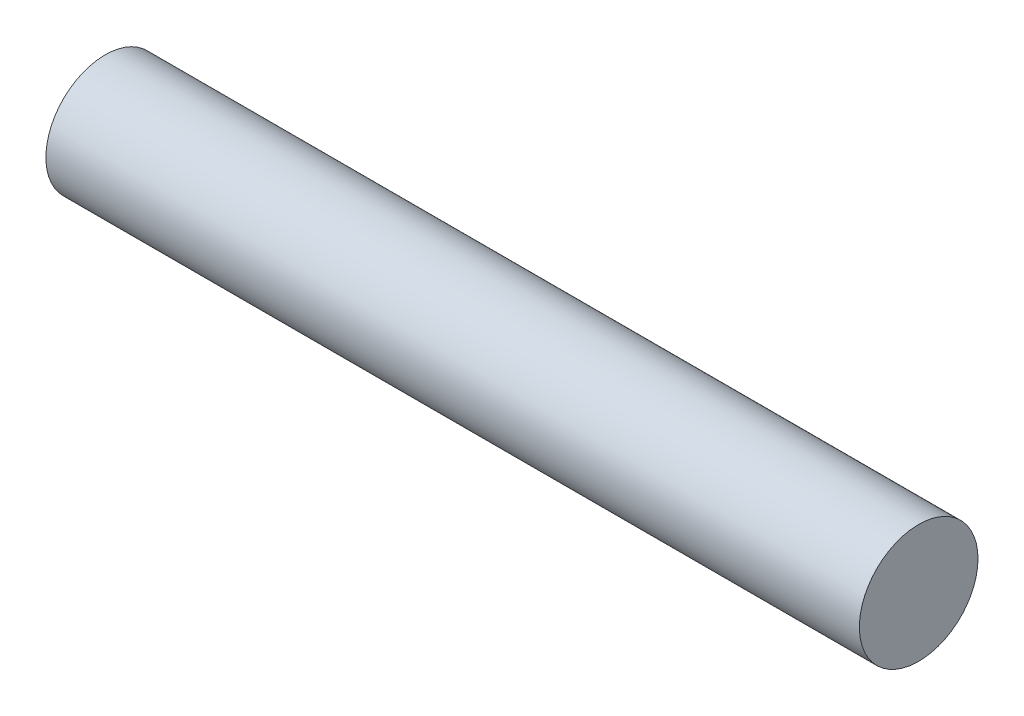
from build123d import *

# Parameters (mm, degrees)
SKETCH1_R           = 11.1125
BOSS_EXTRUDE1_DEPTH = 76.2


with BuildPart() as part:
    # Sketch1 → Boss-Extrude1 (new body, symmetric)
    with BuildSketch(Plane(origin=(0, 0, 0), x_dir=(0, 0, -1), z_dir=(1, 0, 0))):
        Circle(SKETCH1_R)
    extrude(amount=BOSS_EXTRUDE1_DEPTH, both=True)


solid = part.part
